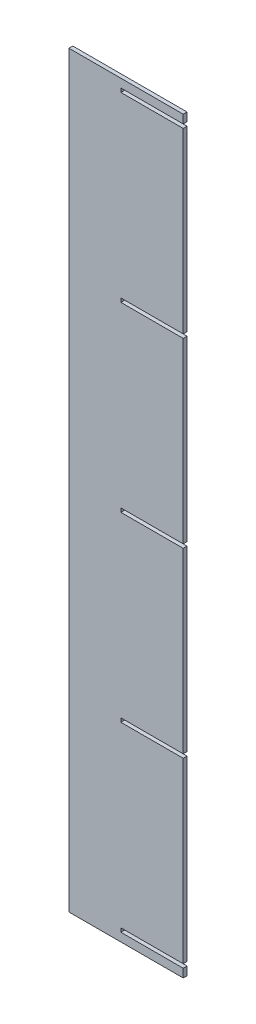
from build123d import *

# Parameters (mm, degrees)
BOSS_EXTRUDE1_DEPTH = 9.398


with BuildPart() as part:
    # Sketch1 → Boss-Extrude1 (new body)
    with BuildSketch(Plane.XY):
        Polygon((25466.620933217, 8828.751571885), (25466.620933217, 6999.951571885), (25746.020933217, 6999.951571885), (25746.020933217, 7020.652571885), (25593.620933217, 7020.652571885), (25593.620933217, 7030.050571885), (25746.020933217, 7030.050571885), (25746.020933217, 7465.152571885), (25593.620933217, 7465.152571885), (25593.620933217, 7474.550571885), (25746.020933217, 7474.550571885), (25746.020933217, 7909.652571885), (25593.620933217, 7909.652571885), (25593.620933217, 7919.050571885), (25746.020933217, 7919.050571885), (25746.020933217, 8354.152571885), (25593.620933217, 8354.152571885), (25593.620933217, 8363.550571885), (25746.020933217, 8363.550571885), (25746.020933217, 8798.652571885), (25593.620933217, 8798.652571885), (25593.620933217, 8808.050571885), (25746.020933217, 8808.050571885), (25746.020933217, 8828.751571885), align=None)
    extrude(amount=BOSS_EXTRUDE1_DEPTH)


solid = part.part
